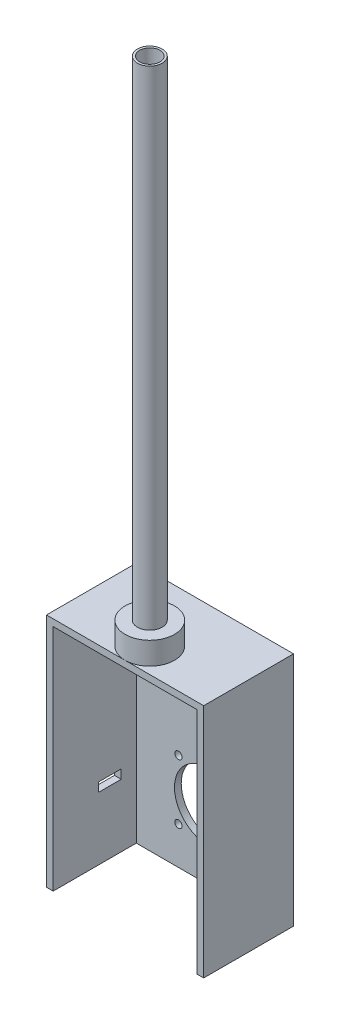
from build123d import *

# Parameters (mm, degrees)
SKETCH_1_R          = 22
EXTRUDE_1_DEPTH     = 20
SKETCH_2_R          = 11
EXTRUDE_2_DEPTH     = 435
SKETCH_4_W          = 140
SKETCH_4_H          = 80
EXTRUDE_3_DEPTH     = 210
SHELL_2_T           = -6
SKETCH_3_R          = 8
CUT_EXTRUDE_2_DEPTH = 461
SKETCH_5_W          = 128
SKETCH_5_H          = 6
CUT_EXTRUDE_3_DEPTH = 74
SKETCH_6_R          = 30
SKETCH_6_R_2        = 3.25
CUT_EXTRUDE_4_DEPTH = 10
SKETCH_7_R          = 9
CUT_EXTRUDE_5_DEPTH = 18
SKETCH_8_R          = 9
CUT_EXTRUDE_6_DEPTH = 18
SKETCH_9_W          = 20
SKETCH_9_H          = 8
CUT_EXTRUDE_7_DEPTH = 10


with BuildPart() as part:
    # 草图1 → 凸台-拉伸1 (new body)
    with BuildSketch(Plane(origin=(0, 0, 0), x_dir=(1, 0, 0), z_dir=(0, 1, 0))):
        Circle(SKETCH_1_R)
    extrude(amount=EXTRUDE_1_DEPTH)

    # 草图2 → 凸台-拉伸2 (add)
    with BuildSketch(Plane(origin=(0, 20, 0), x_dir=(1, 0, 0), z_dir=(0, 1, 0))):
        Circle(SKETCH_2_R)
    extrude(amount=EXTRUDE_2_DEPTH)


with BuildPart() as body_2:
    # 草图4 → 凸台-拉伸3 (new body)
    with BuildSketch(Plane.XZ):
        with Locations((0, -18)):
            Rectangle(SKETCH_4_W, SKETCH_4_H)
    extrude(amount=EXTRUDE_3_DEPTH)

    # 抽壳2
    shell_2_openings = [body_2.faces().sort_by_distance(p)[0] for p in [
        (0, -105, 22),
    ]]
    offset(amount=SHELL_2_T, openings=shell_2_openings, kind=Kind.INTERSECTION)


with BuildPart() as cut_extrude_2_tool:
    # 草图3 → 切除-拉伸2 (new body)
    with BuildSketch(Plane(origin=(0, 455, 0), x_dir=(1, 0, 0), z_dir=(0, 1, 0))):
        Circle(SKETCH_3_R)
    extrude(amount=-CUT_EXTRUDE_2_DEPTH)


with BuildPart() as part_1:
    add(part.part)

    # 切除-拉伸2: cut by cut_extrude_2_tool
    add(cut_extrude_2_tool.part, mode=Mode.SUBTRACT)

    # 草图7 → 切除-拉伸5 (cut)
    with BuildSketch(Plane(origin=(0, 455, 0), x_dir=(1, 0, 0), z_dir=(0, 1, 0))):
        Circle(SKETCH_7_R)
    extrude(amount=-CUT_EXTRUDE_5_DEPTH, mode=Mode.SUBTRACT)


with BuildPart() as body_2_1:
    add(body_2.part)

    # 切除-拉伸2: cut by cut_extrude_2_tool
    add(cut_extrude_2_tool.part, mode=Mode.SUBTRACT)

    # 草图5 → 切除-拉伸3 (cut)
    with BuildSketch(Plane.XY.offset(22)):
        with Locations((0, -207)):
            Rectangle(SKETCH_5_W, SKETCH_5_H)
    extrude(amount=-CUT_EXTRUDE_3_DEPTH, mode=Mode.SUBTRACT)

    # 草图6 → 切除-拉伸4 (cut)
    with BuildSketch(Plane(origin=(0, 0, -58), x_dir=(-1, 0, 0), z_dir=(0, 0, -1))):
        with Locations((0, -150)):
            Circle(SKETCH_6_R)
        with Locations((26.516504294, -123.483495706)):
            Circle(SKETCH_6_R_2)
        with Locations((26.516504294, -176.516504294)):
            Circle(SKETCH_6_R_2)
        with Locations((-26.516504294, -176.516504294)):
            Circle(SKETCH_6_R_2)
        with Locations((-26.516504294, -123.483495706)):
            Circle(SKETCH_6_R_2)
    extrude(amount=-CUT_EXTRUDE_4_DEPTH, mode=Mode.SUBTRACT)


with BuildPart() as cut_extrude_6_tool:
    # 草图8 → 切除-拉伸6 (new body)
    with BuildSketch(Plane.XZ.offset(6)):
        Circle(SKETCH_8_R)
    extrude(amount=-CUT_EXTRUDE_6_DEPTH)


with BuildPart() as part_2:
    add(part_1.part)

    # 切除-拉伸6: cut by cut_extrude_6_tool
    add(cut_extrude_6_tool.part, mode=Mode.SUBTRACT)


with BuildPart() as body_2_2:
    add(body_2_1.part)

    # 切除-拉伸6: cut by cut_extrude_6_tool
    add(cut_extrude_6_tool.part, mode=Mode.SUBTRACT)

    # 草图9 → 切除-拉伸7 (cut)
    with BuildSketch(Plane.ZY.offset(70)):
        with Locations((-28.5, -150)):
            Rectangle(SKETCH_9_W, SKETCH_9_H)
    extrude(amount=-CUT_EXTRUDE_7_DEPTH, mode=Mode.SUBTRACT)


solid = Compound([part_2.part, body_2_2.part])
